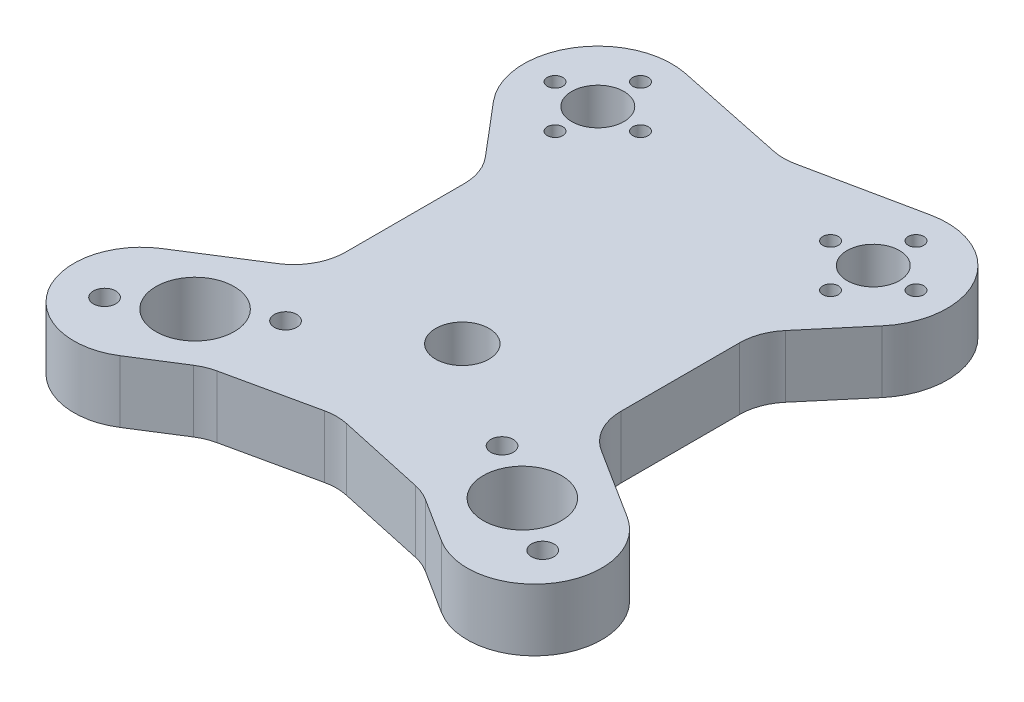
from build123d import *

# Parameters (mm, degrees)
SKETCH1_R           = 5.15
SKETCH1_R_2         = 7.55
SKETCH1_R_3         = 5.05
SKETCH1_R_4         = 1.5
SKETCH1_R_5         = 2.165
BOSS_EXTRUDE1_DEPTH = 12


with BuildPart() as part:
    # Sketch1 → Boss-Extrude1 (new body)
    with BuildSketch(Plane(origin=(0, 0, 0), x_dir=(1, 0, 0), z_dir=(0, 1, 0))):
        with BuildLine():
            Line((-2.036490016, 62.232628927), (-23.679041405, 66.734453302))
            ThreePointArc((-23.679041405, 66.734453302), (-38.872266056, 60.051931597), (-37.504850395, 43.510458082))
            Line((-37.504850395, 43.510458082), (-28.95403297, 33.398266841))
            ThreePointArc((-28.95403297, 33.398266841), (-27.199588127, 30.379378664), (-26.59, 26.941332001))
            Line((-26.59, 26.941332001), (-26.59, 4.037047599))
            ThreePointArc((-26.59, 4.037047599), (-27.829524982, -0.785200575), (-31.240815491, -4.411989333))
            Line((-31.240815491, -4.411989333), (-44.914180747, -13.06875746))
            ThreePointArc((-44.914180747, -13.06875746), (-48.938899729, -30.983792167), (-31.023865021, -35.008511149))
            Line((-31.023865021, -35.008511149), (-22.386088755, -29.539833551))
            ThreePointArc((-22.386088755, -29.539833551), (-20.83471499, -28.738106539), (-19.167525971, -28.21848405))
            Line((-19.167525971, -28.21848405), (-2.130621725, -24.503257579))
            ThreePointArc((-2.130621725, -24.503257579), (0, -24.273644012), (2.130621725, -24.503257579))
            Line((2.130621725, -24.503257579), (19.167525971, -28.21848405))
            ThreePointArc((19.167525971, -28.21848405), (20.83471499, -28.738106539), (22.386088755, -29.539833551))
            Line((22.386088755, -29.539833551), (31.023865021, -35.008511149))
            ThreePointArc((31.023865021, -35.008511149), (48.938899729, -30.983792167), (44.914180747, -13.06875746))
            Line((44.914180747, -13.06875746), (31.240815491, -4.411989333))
            ThreePointArc((31.240815491, -4.411989333), (27.829524982, -0.785200575), (26.59, 4.037047599))
            Line((26.59, 4.037047599), (26.59, 26.941332001))
            ThreePointArc((26.59, 26.941332001), (27.199588127, 30.379378664), (28.95403297, 33.398266841))
            Line((28.95403297, 33.398266841), (37.504850395, 43.510458082))
            ThreePointArc((37.504850395, 43.510458082), (38.872266056, 60.051931597), (23.679041405, 66.734453302))
            Line((23.679041405, 66.734453302), (2.036490016, 62.232628927))
            ThreePointArc((2.036490016, 62.232628927), (0, 62.023068571), (-2.036490016, 62.232628927))
        make_face()
        Circle(SKETCH1_R, mode=Mode.SUBTRACT)
        with Locations((-31.59, -20)):
            Circle(SKETCH1_R_2, mode=Mode.SUBTRACT)
        with Locations((-26.59, 52.74)):
            Circle(SKETCH1_R_3, mode=Mode.SUBTRACT)
        with Locations((-26.59, 60.99)):
            Circle(SKETCH1_R_4, mode=Mode.SUBTRACT)
        with Locations((-18.34, 52.74)):
            Circle(SKETCH1_R_4, mode=Mode.SUBTRACT)
        with Locations((-26.59, 44.49)):
            Circle(SKETCH1_R_4, mode=Mode.SUBTRACT)
        with Locations((-34.84, 52.74)):
            Circle(SKETCH1_R_4, mode=Mode.SUBTRACT)
        with Locations((-42.286480756, -26.772067589)):
            Circle(SKETCH1_R_5, mode=Mode.SUBTRACT)
        with Locations((-20.893519244, -13.227932411)):
            Circle(SKETCH1_R_5, mode=Mode.SUBTRACT)
        with Locations((20.893519244, -13.227932411)):
            Circle(SKETCH1_R_5, mode=Mode.SUBTRACT)
        with Locations((42.286480756, -26.772067589)):
            Circle(SKETCH1_R_5, mode=Mode.SUBTRACT)
        with Locations((34.84, 52.74)):
            Circle(SKETCH1_R_4, mode=Mode.SUBTRACT)
        with Locations((26.59, 44.49)):
            Circle(SKETCH1_R_4, mode=Mode.SUBTRACT)
        with Locations((18.34, 52.74)):
            Circle(SKETCH1_R_4, mode=Mode.SUBTRACT)
        with Locations((26.59, 60.99)):
            Circle(SKETCH1_R_4, mode=Mode.SUBTRACT)
        with Locations((26.59, 52.74)):
            Circle(SKETCH1_R_3, mode=Mode.SUBTRACT)
        with Locations((31.59, -20)):
            Circle(SKETCH1_R_2, mode=Mode.SUBTRACT)
    extrude(amount=BOSS_EXTRUDE1_DEPTH)


solid = part.part
